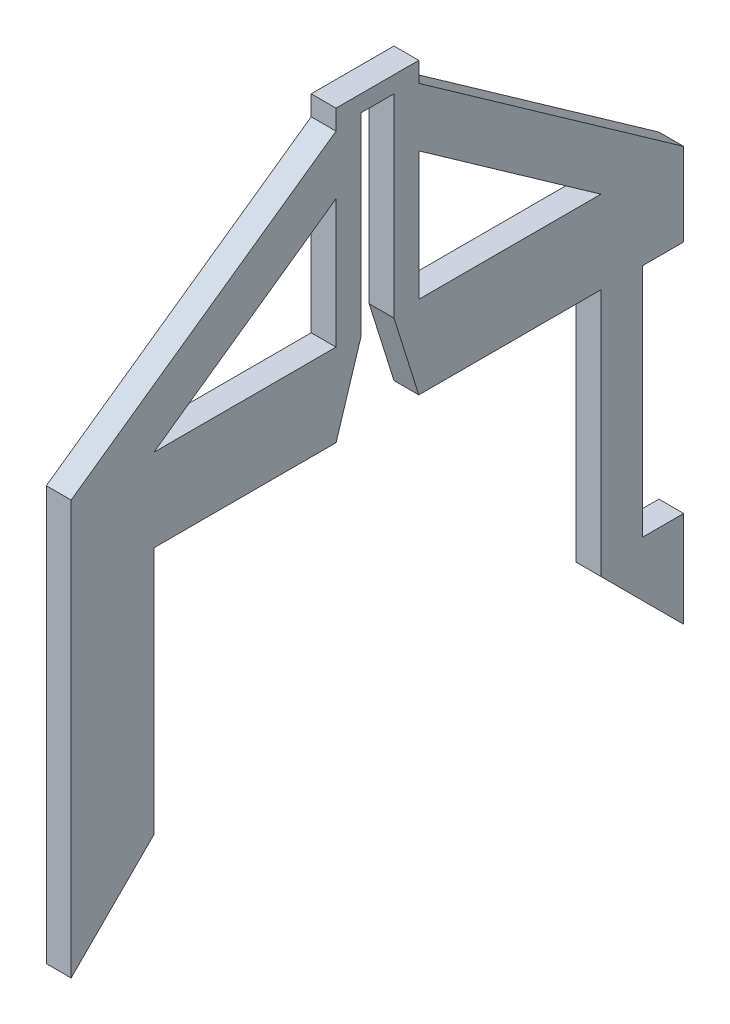
from build123d import *

# Parameters (mm, degrees)
SKETCH2_W           = 74
SKETCH2_H           = 74
SKETCH2_W_2         = 54
SKETCH2_H_2         = 54
BOSS_EXTRUDE1_DEPTH = 3
SKETCH3_W           = 10
SKETCH3_H           = 25
BOSS_EXTRUDE2_DEPTH = 3
CUT_EXTRUDE1_DEPTH  = 3
BOSS_EXTRUDE3_DEPTH = 3
CUT_EXTRUDE2_DEPTH  = 3
CUT_EXTRUDE3_DEPTH  = 3
CUT_EXTRUDE4_DEPTH  = 3
BOSS_EXTRUDE4_DEPTH = 3
CUT_EXTRUDE6_DEPTH  = 3
SKETCH12_W          = 5
SKETCH12_H          = 28.4
CUT_EXTRUDE7_DEPTH  = 3


with BuildPart() as part:
    # Sketch2 → Boss-Extrude1 (new body)
    with BuildSketch(Plane(origin=(0, 0, 0), x_dir=(0, 0, -1), z_dir=(1, 0, 0))):
        Rectangle(SKETCH2_W, SKETCH2_H)
        Rectangle(SKETCH2_W_2, SKETCH2_H_2, mode=Mode.SUBTRACT)
    extrude(amount=BOSS_EXTRUDE1_DEPTH)

    # Sketch3 → Boss-Extrude2 (add)
    with BuildSketch(Plane(origin=(3, 0, 0), x_dir=(0, 0, -1), z_dir=(1, 0, 0))):
        with Locations((0, 49.5)):
            Rectangle(SKETCH3_W, SKETCH3_H)
    extrude(amount=-BOSS_EXTRUDE2_DEPTH)

    # Sketch4 → Cut-Extrude1 (cut)
    with BuildSketch(Plane.ZY):
        with BuildLine():
            ThreePointArc((-5, 57), (-3.535533906, 60.535533906), (0, 62))
            Line((0, 62), (-5, 62))
            Line((-5, 62), (-5, 57))
        make_face()
        with BuildLine():
            ThreePointArc((0, 62), (3.535533906, 60.535533906), (5, 57))
            Line((5, 57), (5, 62))
            Line((5, 62), (0, 62))
        make_face()
    extrude(amount=-CUT_EXTRUDE1_DEPTH, mode=Mode.SUBTRACT)

    # Sketch6 → Boss-Extrude3 (add)
    with BuildSketch(Plane(origin=(3, 0, 0), x_dir=(0, 0, -1), z_dir=(1, 0, 0))):
        with BuildLine():
            Line((0.000702858, 63.122185539), (-37, 37))
            Line((-37, 37), (-27, 37))
            Line((-27, 37), (-5, 52.531815276))
            Line((-5, 52.531815276), (-5, 57))
            ThreePointArc((-5, 57), (0, 62), (5, 57))
            Line((5, 57), (5, 52.531815276))
            Line((5, 52.531815276), (27, 37))
            Line((27, 37), (37, 37))
            Line((37, 37), (0.000702858, 63.122185539))
        make_face()
    extrude(amount=-BOSS_EXTRUDE3_DEPTH)

    # Sketch7 → Cut-Extrude2 (cut)
    with BuildSketch(Plane.ZY):
        with BuildLine():
            Line((2.883065745, 61.086269119), (-0.000702858, 63.122185539))
            Line((-0.000702858, 63.122185539), (-2.884435016, 61.086217499))
            ThreePointArc((-2.884435016, 61.086217499), (-0.000692829, 62.001640055), (2.883065745, 61.086269119))
        make_face()
    extrude(amount=-CUT_EXTRUDE2_DEPTH, mode=Mode.SUBTRACT)

    # Sketch8 → Cut-Extrude3 (cut)
    with BuildSketch(Plane(origin=(3, 0, 0), x_dir=(0, 0, -1), z_dir=(1, 0, 0))):
        with BuildLine():
            ThreePointArc((-27, -22.542313426), (-32.066565807, -20.638358178), (-37, -18.4120694))
            Line((-37, -18.4120694), (-37, -37))
            Line((-37, -37), (37, -37))
            Line((37, -37), (37, -18.412705326))
            ThreePointArc((37, -18.412705326), (32.066562187, -20.638895004), (27, -22.542753385))
            Line((27, -22.542753385), (27, -27))
            Line((27, -27), (0.00064811, -27))
            Line((0.00064811, -27), (-27, -27))
            Line((-27, -27), (-27, -22.542313426))
        make_face()
    extrude(amount=-CUT_EXTRUDE3_DEPTH, mode=Mode.SUBTRACT)

    # Sketch9 → Cut-Extrude4 (cut)
    with BuildSketch(Plane.ZY):
        Polygon((-2.000648078, 36.539392014), (-5.000648078, 27), (4.994412692, 27), (1.999351922, 36.540943925), (1.999351922, 60.001640055), (-2.000648078, 60.001640055), align=None)
    extrude(amount=-CUT_EXTRUDE4_DEPTH, mode=Mode.SUBTRACT)

    # Sketch10 → Boss-Extrude4 (add)
    with BuildSketch(Plane.ZY):
        with BuildLine():
            Line((-5.000648078, 62.001640055), (-5.000648078, 59.592132084))
            Line((-5.000648078, 59.592132084), (-2.884435016, 61.086217499))
            ThreePointArc((-2.884435016, 61.086217499), (-1.513445616, 61.767292541), (-0.000648078, 62.001640055))
            Line((-0.000648078, 62.001640055), (-5.000648078, 62.001640055))
        make_face()
        with BuildLine():
            ThreePointArc((-2.884435016, 61.086217499), (-4.440182664, 59.301755847), (-5.000648078, 57.001640055))
            ThreePointArc((-5.000648078, 57.001640055), (-4.18394821, 54.263027268), (-2.000648078, 52.41906436))
            Line((-2.000648078, 52.41906436), (-2.000648078, 60.001640055))
            Line((-2.000648078, 60.001640055), (1.999351922, 60.001640055))
            Line((1.999351922, 60.001640055), (1.999351922, 52.41906436))
            ThreePointArc((1.999351922, 52.41906436), (4.182652055, 54.263027268), (4.999351922, 57.001640055))
            ThreePointArc((4.999351922, 57.001640055), (4.438865922, 59.301795581), (2.883065745, 61.086269119))
            ThreePointArc((2.883065745, 61.086269119), (1.512106806, 61.76730608), (-0.000648078, 62.001640055))
            ThreePointArc((-0.000648078, 62.001640055), (-1.513445616, 61.767292541), (-2.884435016, 61.086217499))
        make_face()
        with BuildLine():
            Line((4.999351922, 62.001640055), (-0.000648078, 62.001640055))
            ThreePointArc((-0.000648078, 62.001640055), (1.512106806, 61.76730608), (2.883065745, 61.086269119))
            Line((2.883065745, 61.086269119), (4.999351922, 59.592188848))
            Line((4.999351922, 59.592188848), (4.999351922, 62.001640055))
        make_face()
    extrude(amount=-BOSS_EXTRUDE4_DEPTH)

    # Sketch11 → Cut-Extrude6 (cut)
    with BuildSketch(Plane(origin=(3, 0, 0), x_dir=(0, 0, -1), z_dir=(1, 0, 0))):
        Polygon((-27, -3), (-37, -13), (-37, -22.542313426), (-27, -22.542313426), align=None)
        Polygon((27, -3), (27, -22.542753385), (37, -22.542753385), (37, -13), align=None)
    extrude(amount=-CUT_EXTRUDE6_DEPTH, mode=Mode.SUBTRACT)

    # Sketch12 → Cut-Extrude7 (cut)
    with BuildSketch(Plane(origin=(3, 0, 0), x_dir=(0, 0, -1), z_dir=(1, 0, 0))):
        with Locations((34.5, 12.8)):
            Rectangle(SKETCH12_W, SKETCH12_H)
    extrude(amount=-CUT_EXTRUDE7_DEPTH, mode=Mode.SUBTRACT)


solid = part.part
